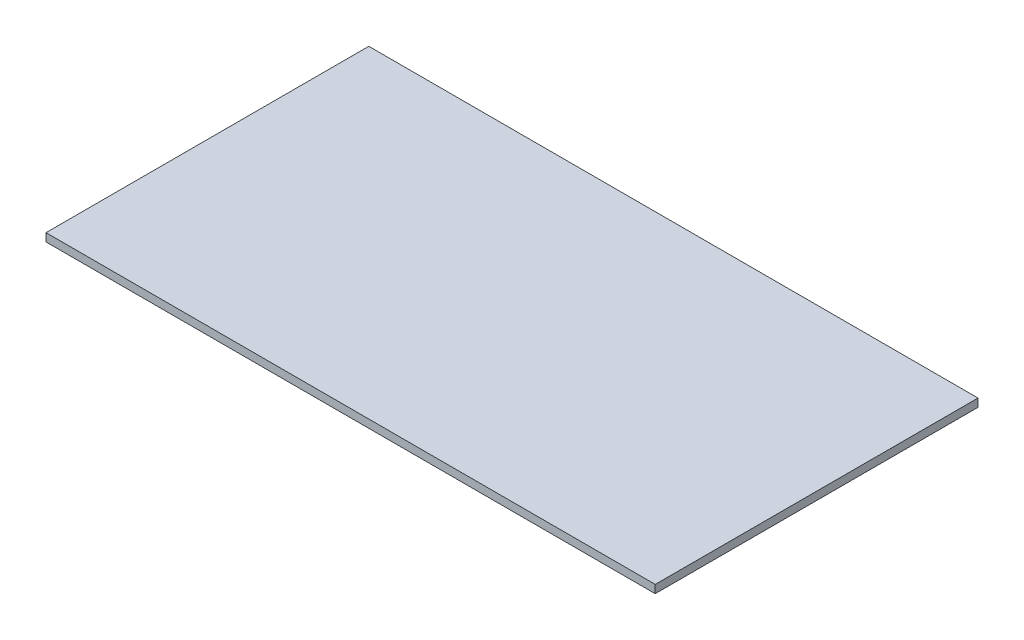
from build123d import *

# Parameters (mm, degrees)
SKETCH1_W           = 155
SKETCH1_H           = 110
BOSS_EXTRUDE1_DEPTH = 80
SKETCH2_W           = 151
SKETCH2_H           = 106
CUT_EXTRUDE1_DEPTH  = 78
SKETCH3_R           = 2.5
CUT_EXTRUDE2_DEPTH  = 2
SKETCH7_R           = 1.6
CUT_EXTRUDE7_DEPTH  = 2
SKETCH4_W           = 27.5
SKETCH4_H           = 46.8
CUT_EXTRUDE8_DEPTH  = 2
SKETCH8_W           = 4
SKETCH8_H           = 53
CUT_EXTRUDE9_DEPTH  = 2
SKETCH9_W           = 14
SKETCH9_H           = 14
CUT_EXTRUDE10_DEPTH = 2
SKETCH10_W          = 25.2
SKETCH10_H          = 71.2
SKETCH10_R          = 1.25
CUT_EXTRUDE12_DEPTH = 2
SKETCH11_R          = 2.5
SKETCH11_R_2        = 4.5
CUT_EXTRUDE13_DEPTH = 2
SKETCH12_W          = 151
SKETCH12_H          = 108
CUT_EXTRUDE14_DEPTH = 80


with BuildPart() as part:
    # Sketch1 → Boss-Extrude1 (new body)
    with BuildSketch(Plane.XY):
        with Locations((77.5, 55)):
            Rectangle(SKETCH1_W, SKETCH1_H)
    extrude(amount=BOSS_EXTRUDE1_DEPTH)

    # Sketch2 → Cut-Extrude1 (cut)
    with BuildSketch(Plane.XY.offset(80)):
        with Locations((77.5, 55)):
            Rectangle(SKETCH2_W, SKETCH2_H)
    extrude(amount=-CUT_EXTRUDE1_DEPTH, mode=Mode.SUBTRACT)

    # Sketch3 → Cut-Extrude2 (cut)
    with BuildSketch(Plane.XY.offset(2)):
        with Locations((145, 100.5)):
            Circle(SKETCH3_R)
        with Locations((145, 9.5)):
            Circle(SKETCH3_R)
        with Locations((10, 9.5)):
            Circle(SKETCH3_R)
        with Locations((10, 100.5)):
            Circle(SKETCH3_R)
    extrude(amount=-CUT_EXTRUDE2_DEPTH, mode=Mode.SUBTRACT)

    # Sketch7 → Cut-Extrude7 (cut)
    with BuildSketch(Plane(origin=(0, 110, 0), x_dir=(1, 0, 0), z_dir=(0, 1, 0))):
        with Locations((44.48, -20.14450396)):
            Circle(SKETCH7_R)
        with Locations((95.28, -17.14)):
            Circle(SKETCH7_R)
        with Locations((95.28, -62.86)):
            Circle(SKETCH7_R)
        with Locations((44.48, -47.62)):
            Circle(SKETCH7_R)
    extrude(amount=-CUT_EXTRUDE7_DEPTH, mode=Mode.SUBTRACT)

    # Sketch4 → Cut-Extrude8 (cut)
    with BuildSketch(Plane(origin=(155, 0, 0), x_dir=(0, 0, -1), z_dir=(1, 0, 0))):
        with Locations((-40, 82.5)):
            Rectangle(SKETCH4_W, SKETCH4_H)
    extrude(amount=-CUT_EXTRUDE8_DEPTH, mode=Mode.SUBTRACT)

    # Sketch8 → Cut-Extrude9 (cut)
    with BuildSketch(Plane(origin=(155, 0, 0), x_dir=(0, 0, -1), z_dir=(1, 0, 0))):
        with Locations((-68, 28.5)):
            Rectangle(SKETCH8_W, SKETCH8_H)
        with Locations((-76, 28.5)):
            Rectangle(SKETCH8_W, SKETCH8_H)
        with Locations((-60, 28.5)):
            Rectangle(SKETCH8_W, SKETCH8_H)
        with Locations((-52, 28.5)):
            Rectangle(SKETCH8_W, SKETCH8_H)
        with Locations((-44, 28.5)):
            Rectangle(SKETCH8_W, SKETCH8_H)
        with Locations((-36, 28.5)):
            Rectangle(SKETCH8_W, SKETCH8_H)
        with Locations((-28, 28.5)):
            Rectangle(SKETCH8_W, SKETCH8_H)
        with Locations((-20, 28.5)):
            Rectangle(SKETCH8_W, SKETCH8_H)
        with Locations((-12, 28.5)):
            Rectangle(SKETCH8_W, SKETCH8_H)
        with Locations((-4, 28.5)):
            Rectangle(SKETCH8_W, SKETCH8_H)
    extrude(amount=-CUT_EXTRUDE9_DEPTH, mode=Mode.SUBTRACT)

    # Sketch9 → Cut-Extrude10 (cut)
    with BuildSketch(Plane(origin=(0, 110, 0), x_dir=(1, 0, 0), z_dir=(0, 1, 0))):
        with Locations((120, -19)):
            Rectangle(SKETCH9_W, SKETCH9_H)
    extrude(amount=-CUT_EXTRUDE10_DEPTH, mode=Mode.SUBTRACT)

    # Sketch10 → Cut-Extrude12 (cut)
    with BuildSketch(Plane.ZY):
        with Locations((58, 55)):
            Rectangle(SKETCH10_W, SKETCH10_H)
        with Locations((42.5, 92.5)):
            Circle(SKETCH10_R)
        with Locations((73.5, 92.5)):
            Circle(SKETCH10_R)
        with Locations((42.5, 17.5)):
            Circle(SKETCH10_R)
        with Locations((73.5, 17.5)):
            Circle(SKETCH10_R)
    extrude(amount=-CUT_EXTRUDE12_DEPTH, mode=Mode.SUBTRACT)

    # Sketch11 → Cut-Extrude13 (cut)
    with BuildSketch(Plane.ZY):
        with Locations((20, 55)):
            Circle(SKETCH11_R)
        with Locations((20, 40)):
            Circle(SKETCH11_R)
        with Locations((20, 25)):
            Circle(SKETCH11_R)
        with Locations((20, 82.5)):
            Circle(SKETCH11_R_2)
    extrude(amount=-CUT_EXTRUDE13_DEPTH, mode=Mode.SUBTRACT)

    # Sketch12 → Cut-Extrude14 (cut)
    with BuildSketch(Plane.XY.offset(80)):
        Polygon((153, 2), (153, 0), (155, 0), (155, 110), (153, 110), align=None)
        with Locations((77.5, 56)):
            Rectangle(SKETCH12_W, SKETCH12_H)
        Polygon((2, 0), (2, 2), (2, 110), (0, 110), (0, 0), align=None)
    extrude(amount=-CUT_EXTRUDE14_DEPTH, mode=Mode.SUBTRACT)


solid = part.part
